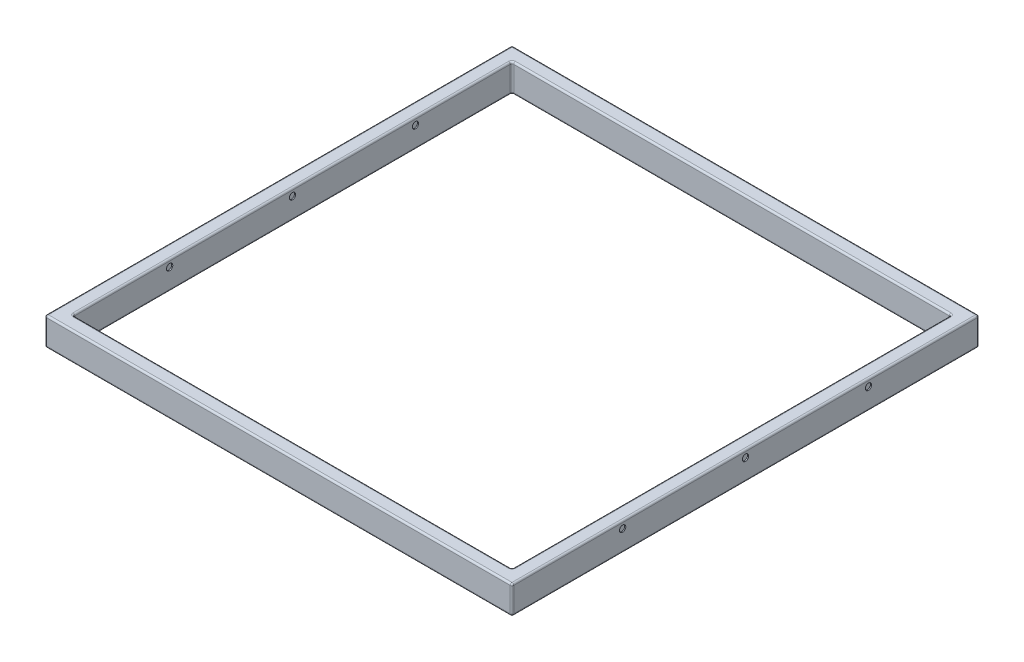
from build123d import *

# Parameters (mm, degrees)
SKETCH1_W           = 1330
SKETCH1_H           = 1330
SKETCH1_W_2         = 1250
SKETCH1_H_2         = 1250
BOSS_EXTRUDE1_DEPTH = 80
FILLET1_R           = 5
SHELL1_T            = 3
SKETCH2_R           = 9
CUT_EXTRUDE1_DEPTH  = 40
SKETCH3_R           = 9
CUT_EXTRUDE2_DEPTH  = 40


with BuildPart() as part:
    # Sketch1 → Boss-Extrude1 (new body)
    with BuildSketch(Plane(origin=(0, 0, 0), x_dir=(1, 0, 0), z_dir=(0, 1, 0))):
        Rectangle(SKETCH1_W, SKETCH1_H)
        Rectangle(SKETCH1_W_2, SKETCH1_H_2, mode=Mode.SUBTRACT)
    extrude(amount=BOSS_EXTRUDE1_DEPTH)

    # Fillet1
    fillet1_edges = [part.edges().sort_by_distance(p)[0] for p in [
        (-665, 80, 0),
        (0, 80, 665),
        (625, 0, 0),
        (625, 40, 625),
        (0, 0, -625),
        (625, 40, -625),
        (-625, 0, 0),
        (-625, 40, -625),
        (0, 0, 625),
        (-625, 40, 625),
        (625, 80, 0),
        (0, 80, -625),
        (-625, 80, 0),
        (0, 80, 625),
        (665, 80, 0),
        (0, 0, 665),
        (-665, 0, 0),
        (0, 0, -665),
        (665, 0, 0),
        (0, 80, -665),
        (665, 40, 665),
        (-665, 40, 665),
        (-665, 40, -665),
        (665, 40, -665),
    ]]
    fillet(fillet1_edges, radius=FILLET1_R)

    # Shell1 (no face opened: a closed hollow body)
    add(offset(amount=-SHELL1_T, mode=Mode.PRIVATE), mode=Mode.SUBTRACT)

    # Sketch2 → Cut-Extrude1 (cut)
    with BuildSketch(Plane(origin=(665, 0, 0), x_dir=(0, 0, -1), z_dir=(1, 0, 0))):
        with Locations((-350, 60)):
            Circle(SKETCH2_R)
        with Locations((0, 60)):
            Circle(SKETCH2_R)
        with Locations((350, 60)):
            Circle(SKETCH2_R)
    extrude(amount=-CUT_EXTRUDE1_DEPTH, mode=Mode.SUBTRACT)

    # Sketch3 → Cut-Extrude2 (cut)
    with BuildSketch(Plane.ZY.offset(665)):
        with Locations((-350, 60)):
            Circle(SKETCH3_R)
        with Locations((0, 60)):
            Circle(SKETCH3_R)
        with Locations((350, 60)):
            Circle(SKETCH3_R)
    extrude(amount=-CUT_EXTRUDE2_DEPTH, mode=Mode.SUBTRACT)


solid = part.part
